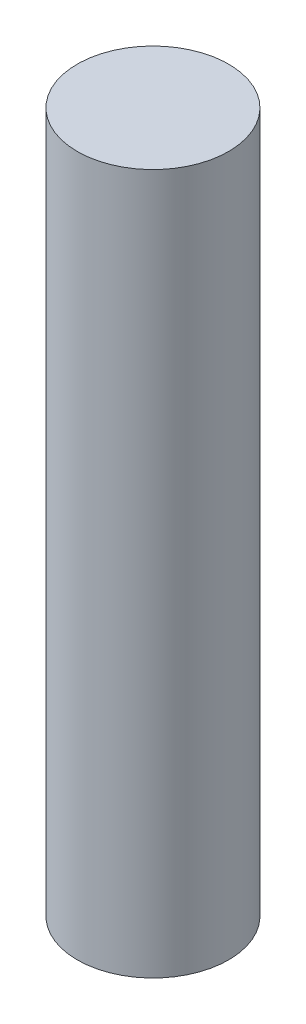
from build123d import *

# Parameters (mm, degrees)
SKETCH1_R           = 0.4
BOSS_EXTRUDE1_DEPTH = 3.7


with BuildPart() as part:
    # Sketch1 → Boss-Extrude1 (new body)
    with BuildSketch(Plane(origin=(0, 0, 0), x_dir=(1, 0, 0), z_dir=(0, 1, 0))):
        Circle(SKETCH1_R)
    extrude(amount=BOSS_EXTRUDE1_DEPTH)


solid = part.part
